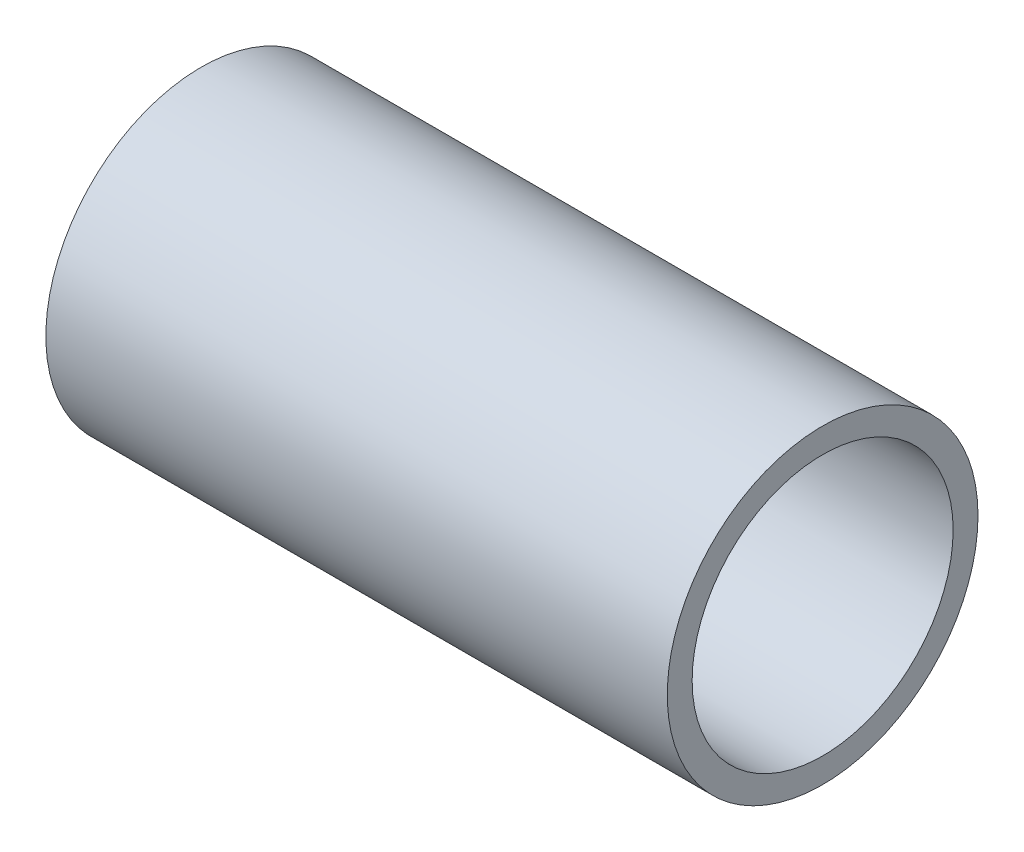
from build123d import *

# Parameters (mm, degrees)
SKETCH1_R           = 9.525
BOSS_EXTRUDE1_DEPTH = 38.1
SKETCH3_R           = 8.509
CUT_EXTRUDE1_DEPTH  = 1.524
SKETCH4_R           = 8.001
CUT_EXTRUDE2_DEPTH  = 37.576


with BuildPart() as part:
    # Sketch1 → Boss-Extrude1 (new body)
    with BuildSketch(Plane(origin=(0, 0, 0), x_dir=(0, 0, -1), z_dir=(1, 0, 0))):
        Circle(SKETCH1_R)
    extrude(amount=BOSS_EXTRUDE1_DEPTH)

    # Sketch3 → Cut-Extrude1 (cut)
    with BuildSketch(Plane.ZY):
        Circle(SKETCH3_R)
    extrude(amount=-CUT_EXTRUDE1_DEPTH, mode=Mode.SUBTRACT)

    # Sketch4 → Cut-Extrude2 (cut, through all)
    with BuildSketch(Plane.ZY.offset(-1.524)):
        Circle(SKETCH4_R)
    extrude(amount=-CUT_EXTRUDE2_DEPTH, mode=Mode.SUBTRACT)


solid = part.part
